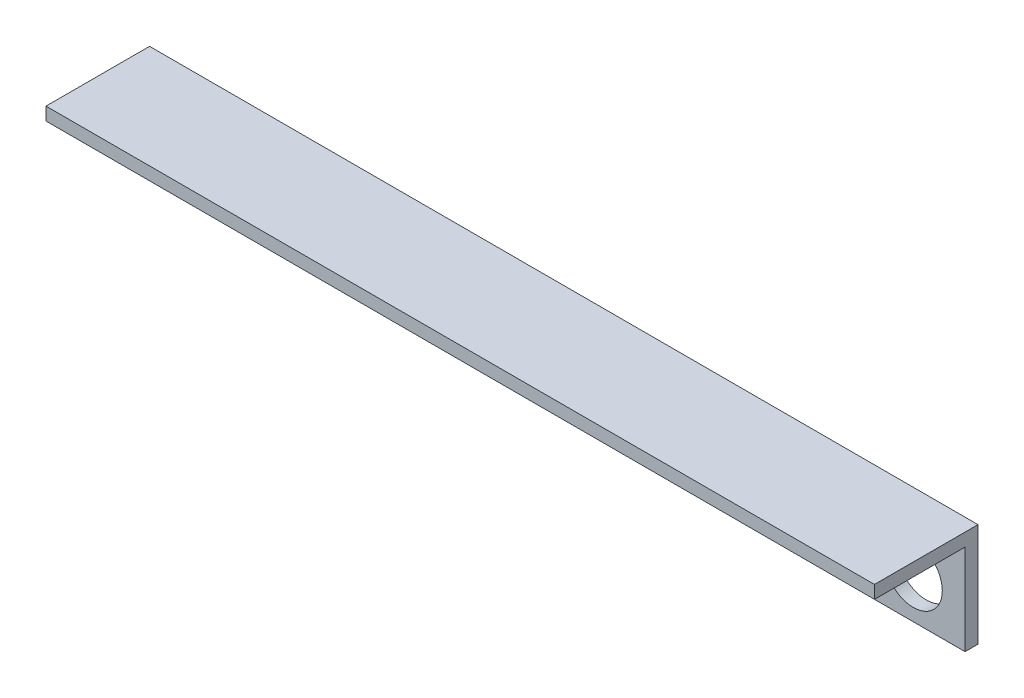
from build123d import *

# Parameters (mm, degrees)
BOSS_EXTRUDE1_DEPTH      = 57.15
BOSS_EXTRUDE1_DEPTH_BACK = 44.45
SKETCH3_R                = 3.556
CUT_EXTRUDE1_DEPTH       = 13.7


with BuildPart() as part:
    # Sketch1 → Boss-Extrude1 (new body, two sides)
    with BuildSketch(Plane(origin=(0, 0, 0), x_dir=(0, 0, -1), z_dir=(1, 0, 0))) as boss_extrude1_sk:
        Polygon((0, 0), (0, 12.7), (-12.7, 12.7), (-12.7, 11.1125), (-1.5875, 11.1125), (-1.5875, 0), align=None)
    extrude(amount=BOSS_EXTRUDE1_DEPTH)
    extrude(boss_extrude1_sk.sketch, amount=-BOSS_EXTRUDE1_DEPTH_BACK)

    # Sketch3 → Cut-Extrude1 (cut, through all)
    with BuildSketch(Plane(origin=(0, 0, 0), x_dir=(-1, 0, 0), z_dir=(0, 0, -1))):
        with Locations((25.4, 5.08)):
            Circle(SKETCH3_R)
        with Locations((-50.8, 5.08)):
            Circle(SKETCH3_R)
    extrude(amount=-CUT_EXTRUDE1_DEPTH, mode=Mode.SUBTRACT)


solid = part.part
